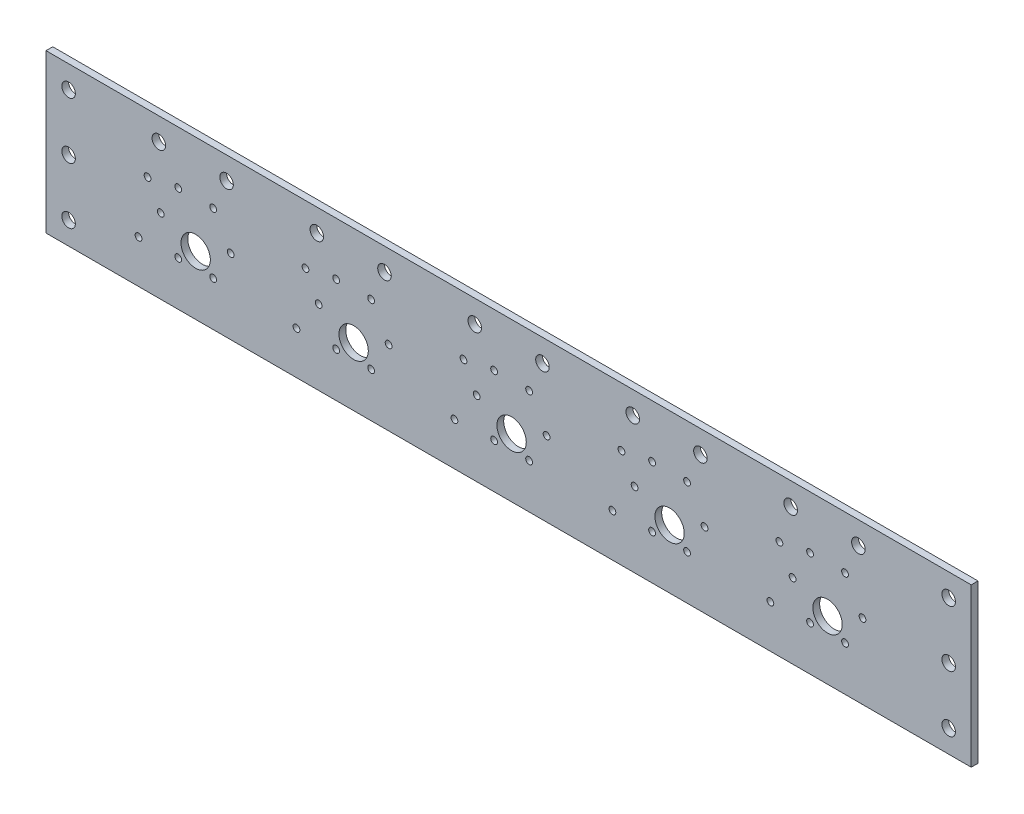
from build123d import *

# Parameters (mm, degrees)
SKETCH_1_W      = 410
SKETCH_1_H      = 70
SKETCH_1_R      = 3
SKETCH_1_R_2    = 6.5
SKETCH_1_R_3    = 1.5
EXTRUDE_1_DEPTH = 3


with BuildPart() as part:
    # 草图1 → 凸台-拉伸1 (new body)
    with BuildSketch(Plane.XY):
        with Locations((205, 35)):
            Rectangle(SKETCH_1_W, SKETCH_1_H)
        with Locations((10, 60)):
            Circle(SKETCH_1_R, mode=Mode.SUBTRACT)
        with Locations((50, 60)):
            Circle(SKETCH_1_R, mode=Mode.SUBTRACT)
        with Locations((80, 60)):
            Circle(SKETCH_1_R, mode=Mode.SUBTRACT)
        with Locations((120, 60)):
            Circle(SKETCH_1_R, mode=Mode.SUBTRACT)
        with Locations((150, 60)):
            Circle(SKETCH_1_R, mode=Mode.SUBTRACT)
        with Locations((190, 60)):
            Circle(SKETCH_1_R, mode=Mode.SUBTRACT)
        with Locations((220, 60)):
            Circle(SKETCH_1_R, mode=Mode.SUBTRACT)
        with Locations((260, 60)):
            Circle(SKETCH_1_R, mode=Mode.SUBTRACT)
        with Locations((290, 60)):
            Circle(SKETCH_1_R, mode=Mode.SUBTRACT)
        with Locations((330, 60)):
            Circle(SKETCH_1_R, mode=Mode.SUBTRACT)
        with Locations((360, 60)):
            Circle(SKETCH_1_R, mode=Mode.SUBTRACT)
        with Locations((400, 60)):
            Circle(SKETCH_1_R, mode=Mode.SUBTRACT)
        with Locations((66.32685934, 26.157789308)):
            Circle(SKETCH_1_R_2, mode=Mode.SUBTRACT)
        with Locations((136.32685934, 26.157789308)):
            Circle(SKETCH_1_R_2, mode=Mode.SUBTRACT)
        with Locations((206.32685934, 26.157789308)):
            Circle(SKETCH_1_R_2, mode=Mode.SUBTRACT)
        with Locations((276.32685934, 26.157789308)):
            Circle(SKETCH_1_R_2, mode=Mode.SUBTRACT)
        with Locations((346.32685934, 26.157789308)):
            Circle(SKETCH_1_R_2, mode=Mode.SUBTRACT)
        with Locations((81.82685934, 33.157789308)):
            Circle(SKETCH_1_R_3, mode=Mode.SUBTRACT)
        with Locations((74.07685934, 19.73439555)):
            Circle(SKETCH_1_R_3, mode=Mode.SUBTRACT)
        with Locations((58.57685934, 19.73439555)):
            Circle(SKETCH_1_R_3, mode=Mode.SUBTRACT)
        with Locations((50.82685934, 33.157789308)):
            Circle(SKETCH_1_R_3, mode=Mode.SUBTRACT)
        with Locations((58.57685934, 46.581183067)):
            Circle(SKETCH_1_R_3, mode=Mode.SUBTRACT)
        with Locations((74.07685934, 46.581183067)):
            Circle(SKETCH_1_R_3, mode=Mode.SUBTRACT)
        with Locations((128.57685934, 46.581183067)):
            Circle(SKETCH_1_R_3, mode=Mode.SUBTRACT)
        with Locations((120.82685934, 33.157789308)):
            Circle(SKETCH_1_R_3, mode=Mode.SUBTRACT)
        with Locations((128.57685934, 19.73439555)):
            Circle(SKETCH_1_R_3, mode=Mode.SUBTRACT)
        with Locations((144.07685934, 19.73439555)):
            Circle(SKETCH_1_R_3, mode=Mode.SUBTRACT)
        with Locations((144.07685934, 46.581183067)):
            Circle(SKETCH_1_R_3, mode=Mode.SUBTRACT)
        with Locations((151.82685934, 33.157789308)):
            Circle(SKETCH_1_R_3, mode=Mode.SUBTRACT)
        with Locations((198.57685934, 46.581183067)):
            Circle(SKETCH_1_R_3, mode=Mode.SUBTRACT)
        with Locations((190.82685934, 33.157789308)):
            Circle(SKETCH_1_R_3, mode=Mode.SUBTRACT)
        with Locations((198.57685934, 19.73439555)):
            Circle(SKETCH_1_R_3, mode=Mode.SUBTRACT)
        with Locations((214.07685934, 19.73439555)):
            Circle(SKETCH_1_R_3, mode=Mode.SUBTRACT)
        with Locations((214.07685934, 46.581183067)):
            Circle(SKETCH_1_R_3, mode=Mode.SUBTRACT)
        with Locations((221.82685934, 33.157789308)):
            Circle(SKETCH_1_R_3, mode=Mode.SUBTRACT)
        with Locations((268.57685934, 46.581183067)):
            Circle(SKETCH_1_R_3, mode=Mode.SUBTRACT)
        with Locations((260.82685934, 33.157789308)):
            Circle(SKETCH_1_R_3, mode=Mode.SUBTRACT)
        with Locations((268.57685934, 19.73439555)):
            Circle(SKETCH_1_R_3, mode=Mode.SUBTRACT)
        with Locations((284.07685934, 19.73439555)):
            Circle(SKETCH_1_R_3, mode=Mode.SUBTRACT)
        with Locations((284.07685934, 46.581183067)):
            Circle(SKETCH_1_R_3, mode=Mode.SUBTRACT)
        with Locations((291.82685934, 33.157789308)):
            Circle(SKETCH_1_R_3, mode=Mode.SUBTRACT)
        with Locations((338.57685934, 46.581183067)):
            Circle(SKETCH_1_R_3, mode=Mode.SUBTRACT)
        with Locations((330.82685934, 33.157789308)):
            Circle(SKETCH_1_R_3, mode=Mode.SUBTRACT)
        with Locations((338.57685934, 19.73439555)):
            Circle(SKETCH_1_R_3, mode=Mode.SUBTRACT)
        with Locations((354.07685934, 19.73439555)):
            Circle(SKETCH_1_R_3, mode=Mode.SUBTRACT)
        with Locations((354.07685934, 46.581183067)):
            Circle(SKETCH_1_R_3, mode=Mode.SUBTRACT)
        with Locations((361.82685934, 33.157789308)):
            Circle(SKETCH_1_R_3, mode=Mode.SUBTRACT)
        with Locations((325, 44)):
            Circle(SKETCH_1_R_3, mode=Mode.SUBTRACT)
        with Locations((321, 19)):
            Circle(SKETCH_1_R_3, mode=Mode.SUBTRACT)
        with Locations((255, 44)):
            Circle(SKETCH_1_R_3, mode=Mode.SUBTRACT)
        with Locations((251, 19)):
            Circle(SKETCH_1_R_3, mode=Mode.SUBTRACT)
        with Locations((185, 44)):
            Circle(SKETCH_1_R_3, mode=Mode.SUBTRACT)
        with Locations((181, 19)):
            Circle(SKETCH_1_R_3, mode=Mode.SUBTRACT)
        with Locations((115, 44)):
            Circle(SKETCH_1_R_3, mode=Mode.SUBTRACT)
        with Locations((111, 19)):
            Circle(SKETCH_1_R_3, mode=Mode.SUBTRACT)
        with Locations((45, 44)):
            Circle(SKETCH_1_R_3, mode=Mode.SUBTRACT)
        with Locations((41, 19)):
            Circle(SKETCH_1_R_3, mode=Mode.SUBTRACT)
        with Locations((400, 10)):
            Circle(SKETCH_1_R, mode=Mode.SUBTRACT)
        with Locations((10, 10)):
            Circle(SKETCH_1_R, mode=Mode.SUBTRACT)
        with Locations((10, 35)):
            Circle(SKETCH_1_R, mode=Mode.SUBTRACT)
        with Locations((400, 35)):
            Circle(SKETCH_1_R, mode=Mode.SUBTRACT)
    extrude(amount=EXTRUDE_1_DEPTH)


solid = part.part
